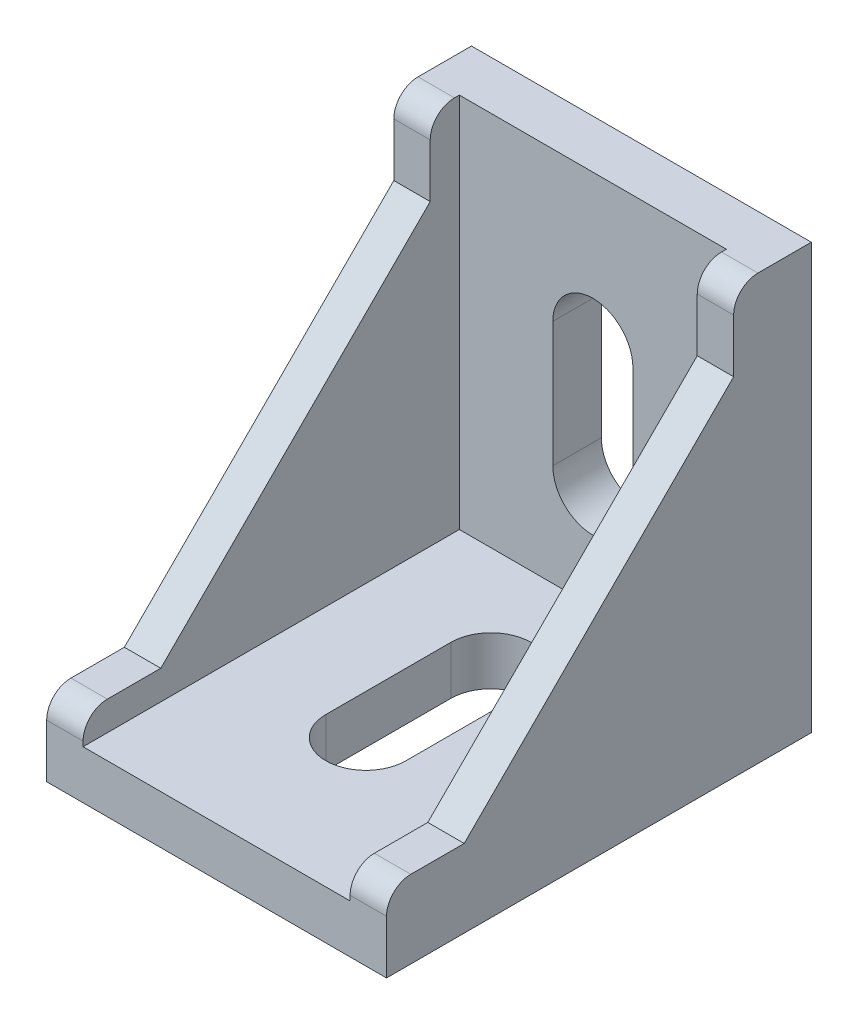
from build123d import *

# Parameters (mm, degrees)
SKETCH1_W           = 35
SKETCH1_H           = 35
BOSS_EXTRUDE1_DEPTH = 14
CUT_EXTRUDE1_DEPTH  = 57.868268832
SKETCH3_W           = 22
SKETCH3_H           = 31
CUT_EXTRUDE2_DEPTH  = 31
CUT_EXTRUDE3_DEPTH  = 57.868268832
FILLET1_R           = 2
CUT_EXTRUDE4_DEPTH  = 49.805737368
CUT_EXTRUDE5_DEPTH  = 49.805737368
SKETCH7_W           = 5.8
SKETCH7_H           = 2.6
BOSS_EXTRUDE2_DEPTH = 2.1
SKETCH8_W           = 5.8
SKETCH8_H           = 2.6
BOSS_EXTRUDE3_DEPTH = 2.1


with BuildPart() as part:
    # Sketch1 → Boss-Extrude1 (new, symmetric)
    with BuildSketch(Plane(origin=(0, 0, 0), x_dir=(0, 0, -1), z_dir=(1, 0, 0))):
        with Locations((-17.5, 17.5)):
            Rectangle(SKETCH1_W, SKETCH1_H)
    extrude(amount=BOSS_EXTRUDE1_DEPTH, both=True)

    # Sketch2 → Cut-Extrude1 (cut, through all)
    with BuildSketch(Plane.ZY.offset(14)):
        Polygon((35, 35), (6.4, 35), (35, 6.4), align=None)
    extrude(amount=-CUT_EXTRUDE1_DEPTH, mode=Mode.SUBTRACT)

    # Sketch3 → Cut-Extrude2 (cut)
    with BuildSketch(Plane(origin=(0, 35, 0), x_dir=(1, 0, 0), z_dir=(0, 1, 0))):
        with Locations((0, -19.5)):
            Rectangle(SKETCH3_W, SKETCH3_H)
    extrude(amount=-CUT_EXTRUDE2_DEPTH, mode=Mode.SUBTRACT)

    # Sketch4 → Cut-Extrude3 (cut, through all)
    with BuildSketch(Plane.ZY.offset(14)):
        Polygon((6.4, 35), (6.4, 28.6), (28.6, 6.4), (35, 6.4), align=None)
    extrude(amount=-CUT_EXTRUDE3_DEPTH, mode=Mode.SUBTRACT)

    # Fillet1
    fillet1_edges = [part.edges().sort_by_distance(p)[0] for p in [
        (12.5, 6.4, 35),
        (12.5, 35, 6.4),
        (-12.5, 6.4, 35),
        (-12.5, 35, 6.4),
    ]]
    fillet(fillet1_edges, radius=FILLET1_R)

    # Sketch5 → Cut-Extrude4 (cut, through all)
    with BuildSketch(Plane.XY.offset(4)):
        with BuildLine():
            Line((-3.3, 12.4), (-3.3, 22.7))
            ThreePointArc((-3.3, 22.7), (0, 26), (3.3, 22.7))
            Line((3.3, 22.7), (3.3, 12.4))
            ThreePointArc((3.3, 12.4), (0, 9.1), (-3.3, 12.4))
        make_face()
    extrude(amount=-CUT_EXTRUDE4_DEPTH, mode=Mode.SUBTRACT)

    # Sketch6 → Cut-Extrude5 (cut, through all)
    with BuildSketch(Plane(origin=(0, 4, 0), x_dir=(1, 0, 0), z_dir=(0, 1, 0))):
        with BuildLine():
            Line((3.3, -12.4), (3.3, -22.7))
            ThreePointArc((3.3, -22.7), (0, -26), (-3.3, -22.7))
            Line((-3.3, -22.7), (-3.3, -12.4))
            ThreePointArc((-3.3, -12.4), (0, -9.1), (3.3, -12.4))
        make_face()
    extrude(amount=-CUT_EXTRUDE5_DEPTH, mode=Mode.SUBTRACT)

    # Sketch7 → Boss-Extrude2 (add)
    with BuildSketch(Plane(origin=(0, 0, 0), x_dir=(-1, 0, 0), z_dir=(0, 0, -1))):
        with Locations((0, 31)):
            Rectangle(SKETCH7_W, SKETCH7_H)
        with Locations((0, 4)):
            Rectangle(SKETCH7_W, SKETCH7_H)
    extrude(amount=BOSS_EXTRUDE2_DEPTH)

    # Sketch8 → Boss-Extrude3 (add)
    with BuildSketch(Plane.XZ):
        with Locations((0, 31)):
            Rectangle(SKETCH8_W, SKETCH8_H)
        with Locations((0, 4)):
            Rectangle(SKETCH8_W, SKETCH8_H)
    extrude(amount=BOSS_EXTRUDE3_DEPTH)


solid = part.part
